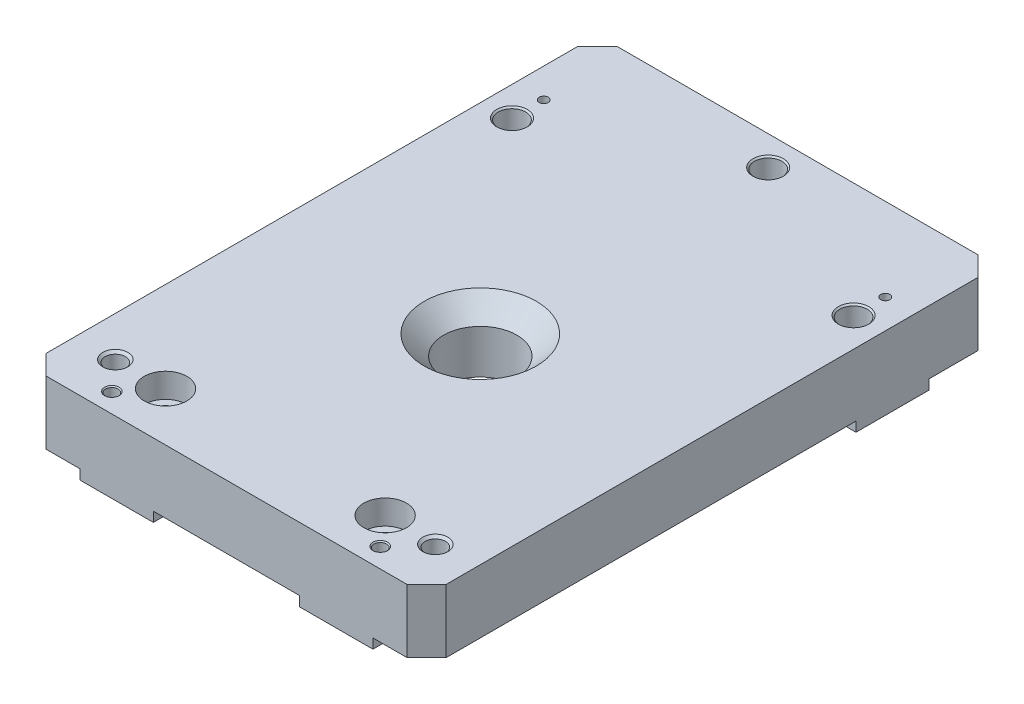
from build123d import *

# Parameters (mm, degrees)
SKETCH41_W                                    = 104.14
SKETCH41_H                                    = 148.59
SKETCH41_R                                    = 9.525
EXTRUDE16_DEPTH                               = 16.51
SKETCH42_W                                    = 19.05
SKETCH42_H                                    = 19.05
SKETCH42_W_2                                  = 13.97
SKETCH42_W_3                                  = 12.7
SKETCH42_H_2                                  = 15.24
EXTRUDE17_DEPTH                               = 2.54
F_1_4_CLEARANCE_HOLE3_AT_2_COUNT              = 2
F_1_4_CLEARANCE_HOLE3_AT_2_PITCH              = 88.9
F_1_4_CLEARANCE_HOLE3_AT_3_COUNT              = 2
F_1_4_CLEARANCE_HOLE3_AT_3_PITCH              = 49.6966108
PRESS_PIN_HOLES_FOR_MAGNET_BRACKET_P_2_COUNT  = 2
PRESS_PIN_HOLES_FOR_MAGNET_BRACKET_P_2_PITCH  = 88.9
F_3_32_0_09375_DIAMETER_HOLE1_D               = 2.38125
CBORE_FOR_1_4_SOCKET_HEAD_CAP_SCREW1_AT_COUNT = 2
CBORE_FOR_1_4_SOCKET_HEAD_CAP_SCREW1_AT_PITCH = 57.15
F_1_8_0_125_DIAMETER_HOLE1_AT_2_COUNT         = 2
F_1_8_0_125_DIAMETER_HOLE1_AT_2_PITCH         = 69.85
TAPPED_HOLE_FOR_8_32_HELICOIL1_AT_2_COUNT     = 2
TAPPED_HOLE_FOR_8_32_HELICOIL1_AT_2_PITCH     = 83.29041666
CHAMFER1_SIZE                                 = 5.08


with BuildPart() as part:
    # Sketch41 → Extrude16 (new body)
    with BuildSketch(Plane(origin=(0, 0, 0), x_dir=(1, 0, 0), z_dir=(0, 1, 0))):
        with Locations((0, -36.195)):
            Rectangle(SKETCH41_W, SKETCH41_H)
        with Locations(Location((0, -44.45, 0), (0, 0, 270))):  # turned: the seam where the file's is
            Circle(SKETCH41_R, mode=Mode.SUBTRACT)
    extrude(amount=EXTRUDE16_DEPTH)

    # Sketch42 → Extrude17 (add)
    with BuildSketch(Plane.XZ):
        with Locations((-28.575, 100.965)):
            Rectangle(SKETCH42_W, SKETCH42_H)
        with Locations((45.085, -10.795)):
            Rectangle(SKETCH42_W_2, SKETCH42_H)
        with Locations((0, -30.48)):
            Rectangle(SKETCH42_W_3, SKETCH42_H_2)
        with Locations((-45.085, -10.795)):
            Rectangle(SKETCH42_W_2, SKETCH42_H)
        with Locations((28.575, 100.965)):
            Rectangle(SKETCH42_W, SKETCH42_H)
    extrude(amount=EXTRUDE17_DEPTH)

    # Sketch43 → 1/4 Clearance Hole3 (revolve, cut)
    with BuildSketch(Plane(origin=(-44.45, -2.54, -8.255), x_dir=(0, 0, -1), z_dir=(1, 0, 0))):
        Polygon((0, 0), (0, 19.05), (3.9624, 19.05), (3.57124, 18.65884), (3.57124, 0.39116), (3.9624, 0), align=None)
    f_1_4_clearance_hole3 = revolve(axis=Axis((-44.45, -8.89, -8.255), (0, 1, 0)), mode=Mode.SUBTRACT)

    # 1/4 Clearance Hole3 at 2: 1/4 Clearance Hole3 ×2
    with Locations(*[(i * F_1_4_CLEARANCE_HOLE3_AT_2_PITCH, 0, 0) for i in range(1, F_1_4_CLEARANCE_HOLE3_AT_2_COUNT)]):
        add(f_1_4_clearance_hole3, mode=Mode.SUBTRACT)

    # 1/4 Clearance Hole3 at 3: 1/4 Clearance Hole3 ×2
    with Locations(*[Vector(0.894427191, 0, -0.447213595) * (i * F_1_4_CLEARANCE_HOLE3_AT_3_PITCH) for i in range(1, F_1_4_CLEARANCE_HOLE3_AT_3_COUNT)]):
        add(f_1_4_clearance_hole3, mode=Mode.SUBTRACT)

    # Sketch39 → Press Pin holes for Magnet Bracket Pins (revolve, cut)
    with BuildSketch(Plane(origin=(-44.45, -2.54, -16.51), x_dir=(0, 0, -1), z_dir=(1, 0, 0))):
        Polygon((0, 0), (0, 7.303866233), (1.5875, 6.35), (1.5875, 1.524), (1.6002, 1.524), (1.6002, 0.3048), (1.905, 0), align=None)
    press_pin_holes_for_magnet_bracket_pins = revolve(axis=Axis((-44.45, -8.89, -16.51), (0, 1, 0)), mode=Mode.SUBTRACT)

    # Press Pin holes for Magnet Bracket P 2: Press Pin holes for Magnet Bracket Pins ×2
    with Locations(*[(i * PRESS_PIN_HOLES_FOR_MAGNET_BRACKET_P_2_PITCH, 0, 0) for i in range(1, PRESS_PIN_HOLES_FOR_MAGNET_BRACKET_P_2_COUNT)]):
        add(press_pin_holes_for_magnet_bracket_pins, mode=Mode.SUBTRACT)

    # 3/32 (0.09375) Diameter Hole1 (through all)
    with Locations(Plane(origin=(0, 16.51, 0), x_dir=(-1, 0, 0), z_dir=(0, 1, 0))):
        with Locations((44.45, -16.51), (-44.45, -16.51)):
            Hole(F_3_32_0_09375_DIAMETER_HOLE1_D / 2)

    # Sketch7 → CBORE for 1/4 Socket Head Cap Screw1 (revolve, cut)
    with BuildSketch(Plane(origin=(-28.575, 16.51, 97.79), x_dir=(0, 0, 1), z_dir=(1, 0, 0))):
        Polygon((0, 0), (0, 19.050025), (3.9624, 19.050025), (3.57124, 18.658865), (3.57124, 6.35), (5.55625, 6.35), (5.55625, 0), align=None)
    cbore_for_1_4_socket_head_cap_screw1 = revolve(axis=Axis((-28.575, 22.86, 97.79), (0, -1, 0)), mode=Mode.SUBTRACT)

    # CBORE for 1/4 Socket Head Cap Screw1 at: CBORE for 1/4 Socket Head Cap Screw1 ×2
    with Locations(*[(i * CBORE_FOR_1_4_SOCKET_HEAD_CAP_SCREW1_AT_PITCH, 0, 0) for i in range(1, CBORE_FOR_1_4_SOCKET_HEAD_CAP_SCREW1_AT_COUNT)]):
        add(cbore_for_1_4_socket_head_cap_screw1, mode=Mode.SUBTRACT)

    # Sketch45 → 1/8 (0.125) Diameter Hole1 (revolve, cut)
    with BuildSketch(Plane(origin=(-34.925, -2.54, 105.41), x_dir=(0, 0, -1), z_dir=(1, 0, 0))):
        Polygon((0, 0), (0, 19.05), (1.905, 19.05), (1.63195, 18.77695), (1.63195, 0.27305), (1.905, 0), align=None)
    f_1_8_0_125_diameter_hole1 = revolve(axis=Axis((-34.925, -8.89, 105.41), (0, 1, 0)), mode=Mode.SUBTRACT)

    # 1/8 (0.125) Diameter Hole1 at 2: 1/8 (0.125) Diameter Hole1 ×2
    with Locations(*[(i * F_1_8_0_125_DIAMETER_HOLE1_AT_2_PITCH, 0, 0) for i in range(1, F_1_8_0_125_DIAMETER_HOLE1_AT_2_COUNT)]):
        add(f_1_8_0_125_diameter_hole1, mode=Mode.SUBTRACT)

    # Sketch37 → Tapped Hole for #8-32 Helicoil1 (revolve, cut)
    with BuildSketch(Plane(origin=(-41.64520833, 16.51, 97.79), x_dir=(0, 0, 1), z_dir=(1, 0, 0))):
        Polygon((0, 0), (0, 19.050025), (2.1971, 19.050025), (2.1971, 13.0048), (2.63779, 13.0048), (2.63779, 0.635), (3.27279, 0), align=None)
    tapped_hole_for_8_32_helicoil1 = revolve(axis=Axis((-41.64520833, 22.86, 97.79), (0, -1, 0)), mode=Mode.SUBTRACT)

    # Tapped Hole for #8-32 Helicoil1 at 2: Tapped Hole for #8-32 Helicoil1 ×2
    with Locations(*[(i * TAPPED_HOLE_FOR_8_32_HELICOIL1_AT_2_PITCH, 0, 0) for i in range(1, TAPPED_HOLE_FOR_8_32_HELICOIL1_AT_2_COUNT)]):
        add(tapped_hole_for_8_32_helicoil1, mode=Mode.SUBTRACT)

    # Chamfer1
    chamfer1_edges = [part.edges().sort_by_distance(p)[0] for p in [
        (52.07, 8.255, 110.49),
        (-52.07, 8.255, 110.49),
        (-52.07, 8.255, -38.1),
        (52.07, 8.255, -38.1),
        (0, 16.51, 34.925),
    ]]
    chamfer(chamfer1_edges, length=CHAMFER1_SIZE)


solid = part.part
